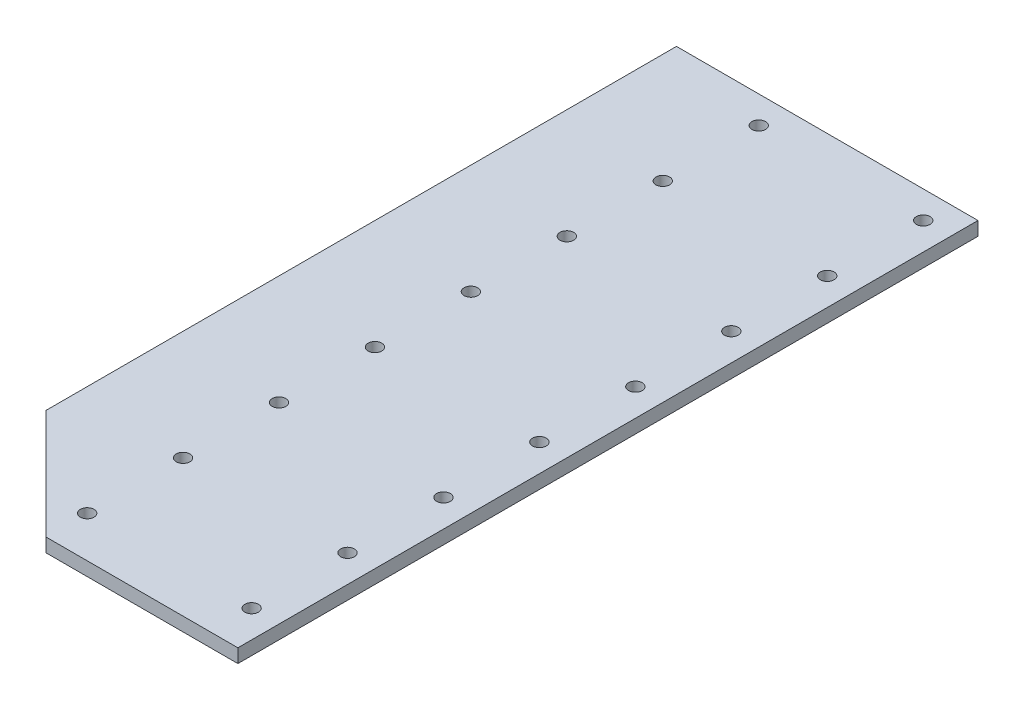
from build123d import *

# Parameters (mm, degrees)
SKETCH1_R           = 2.5
BOSS_EXTRUDE1_DEPTH = 5


with BuildPart() as part:
    # Sketch1 → Boss-Extrude1 (new body)
    with BuildSketch(Plane(origin=(0, 0, 0), x_dir=(1, 0, 0), z_dir=(0, 1, 0))):
        Polygon((0, 0), (0, 230), (110, 230), (110, -35), (110, -40), (40, -40), align=None)
        with Locations((40, 220)):
            Circle(SKETCH1_R, mode=Mode.SUBTRACT)
        with Locations((100, 220)):
            Circle(SKETCH1_R, mode=Mode.SUBTRACT)
        with Locations((40, 185)):
            Circle(SKETCH1_R, mode=Mode.SUBTRACT)
        with Locations((100, 185)):
            Circle(SKETCH1_R, mode=Mode.SUBTRACT)
        with Locations((40, 150)):
            Circle(SKETCH1_R, mode=Mode.SUBTRACT)
        with Locations((100, 150)):
            Circle(SKETCH1_R, mode=Mode.SUBTRACT)
        with Locations((40, 115)):
            Circle(SKETCH1_R, mode=Mode.SUBTRACT)
        with Locations((100, 115)):
            Circle(SKETCH1_R, mode=Mode.SUBTRACT)
        with Locations((40, 80)):
            Circle(SKETCH1_R, mode=Mode.SUBTRACT)
        with Locations((100, 80)):
            Circle(SKETCH1_R, mode=Mode.SUBTRACT)
        with Locations((40, 45)):
            Circle(SKETCH1_R, mode=Mode.SUBTRACT)
        with Locations((100, 45)):
            Circle(SKETCH1_R, mode=Mode.SUBTRACT)
        with Locations((40, 10)):
            Circle(SKETCH1_R, mode=Mode.SUBTRACT)
        with Locations((100, 10)):
            Circle(SKETCH1_R, mode=Mode.SUBTRACT)
        with Locations((40, -25)):
            Circle(SKETCH1_R, mode=Mode.SUBTRACT)
        with Locations((100, -25)):
            Circle(SKETCH1_R, mode=Mode.SUBTRACT)
    extrude(amount=BOSS_EXTRUDE1_DEPTH)


solid = part.part
